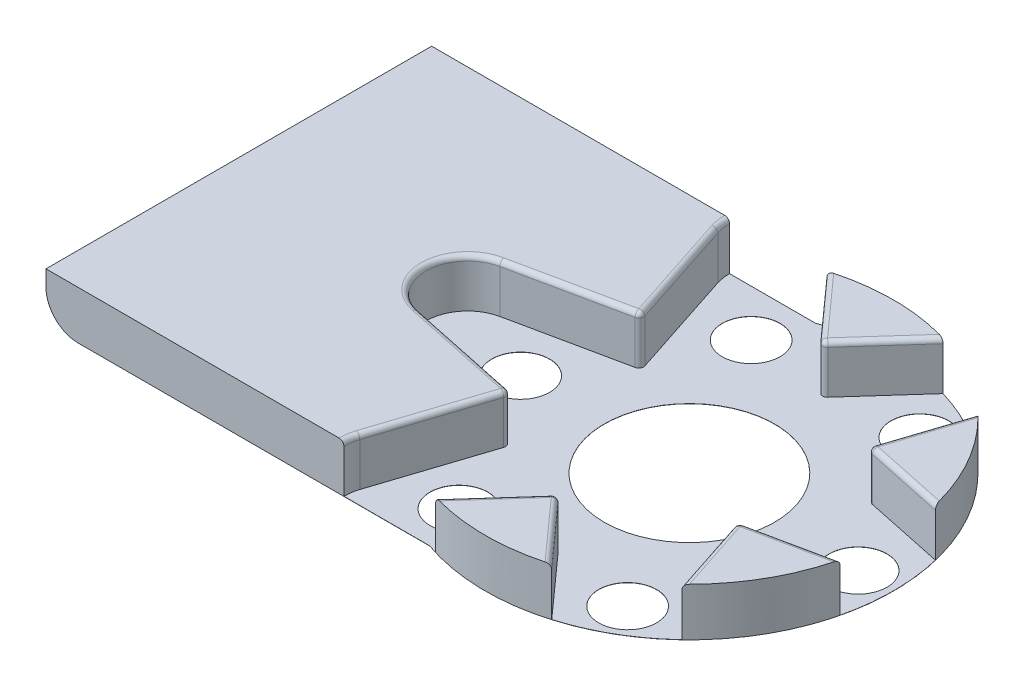
from build123d import *

# Parameters (mm, degrees)
CROQUIS1_R              = 5.3
SALIENTE_EXTRUIR1_DEPTH = 3
CORTAR_EXTRUIR2_DEPTH   = 2.99
REDONDEO1_R             = 2
REDONDEO2_R             = 0.3
CROQUIS3_R              = 1.8
CORTAR_EXTRUIR3_DEPTH   = 10
MATRIZC1_COUNT          = 6


with BuildPart() as part:
    # Croquis1 → Saliente-Extruir1 (new body)
    with BuildSketch(Plane(origin=(0, 0, 0), x_dir=(1, 0, 0), z_dir=(0, 1, 0))):
        with BuildLine():
            Line((-28.04, 12), (-4.158124577, 12))
            ThreePointArc((-4.158124577, 12), (12.7, 0), (-4.158124577, -12))
            Line((-4.158124577, -12), (-28.04, -12))
            Line((-28.04, -12), (-28.04, 12))
        make_face()
        Circle(CROQUIS1_R, mode=Mode.SUBTRACT)
    extrude(amount=SALIENTE_EXTRUIR1_DEPTH)

    # Croquis2 → Cortar-Extruir2 (cut)
    with BuildSketch(Plane(origin=(0, 3, 0), x_dir=(1, 0, 0), z_dir=(0, 1, 0))):
        with BuildLine():
            Line((-14.335178977, -2.544323773), (-7.058107041, -4.075))
            Line((-7.058107041, -4.075), (-9.371038511, -11.142467275))
            ThreePointArc((-9.371038511, -11.142467275), (-8.2, -14.202816622), (-4.964140465, -13.686791048))
            Line((-4.964140465, -13.686791048), (0, -8.15))
            Line((0, -8.15), (4.964140465, -13.686791048))
            ThreePointArc((4.964140465, -13.686791048), (8.2, -14.202816622), (9.371038511, -11.142467275))
            Line((9.371038511, -11.142467275), (7.058107041, -4.075))
            Line((7.058107041, -4.075), (14.335178977, -2.544323773))
            ThreePointArc((14.335178977, -2.544323773), (16.4, 0), (14.335178977, 2.544323773))
            Line((14.335178977, 2.544323773), (7.058107041, 4.075))
            Line((7.058107041, 4.075), (9.371038511, 11.142467275))
            ThreePointArc((9.371038511, 11.142467275), (8.2, 14.202816622), (4.964140465, 13.686791048))
            Line((4.964140465, 13.686791048), (0, 8.15))
            Line((0, 8.15), (-4.964140465, 13.686791048))
            ThreePointArc((-4.964140465, 13.686791048), (-8.2, 14.202816622), (-9.371038511, 11.142467275))
            Line((-9.371038511, 11.142467275), (-7.058107041, 4.075))
            Line((-7.058107041, 4.075), (-14.335178977, 2.544323773))
            ThreePointArc((-14.335178977, 2.544323773), (-16.4, 0), (-14.335178977, -2.544323773))
        make_face()
    extrude(amount=-CORTAR_EXTRUIR2_DEPTH, mode=Mode.SUBTRACT)

    # Redondeo1
    redondeo1_edges = [part.edges().sort_by_distance(p)[0] for p in [
        (-28.04, 0, 0),
    ]]
    fillet(redondeo1_edges, radius=REDONDEO1_R)

    # Redondeo2
    redondeo2_edges = [part.edges().sort_by_distance(p)[0] for p in [
        (0, 1.505, -8.15),
        (7.058107041, 1.505, -4.075),
        (7.058107041, 1.505, 4.075),
        (0, 1.505, 8.15),
        (1.804886558, 3, 10.163093668),
        (7.899054019, 3, 6.644624444),
        (9.703940577, 3, 3.518469224),
        (9.703940577, 3, -3.518469224),
        (7.899054019, 3, -6.644624444),
        (1.804886558, 3, -10.163093668),
        (-1.804886558, 3, -10.163093668),
        (-9.471290512, 3, -11.565838876),
        (-8.214572776, 3, -7.608733638),
        (-10.696643009, 3, -3.309661887),
        (-16.4, 3, 0),
        (-10.696643009, 3, 3.309661887),
        (-8.214572776, 3, 7.608733638),
        (-9.471290512, 3, 11.565838876),
        (-1.804886558, 3, 10.163093668),
        (-7.058107041, 1.505, -4.075),
        (-7.058107041, 1.505, 4.075),
    ]]
    fillet(redondeo2_edges, radius=REDONDEO2_R)

    # Croquis3 → Cortar-Extruir3 (cut)
    with BuildSketch(Plane.XZ):
        with Locations((10.5, 0)):
            Circle(CROQUIS3_R)
    cortar_extruir3 = extrude(amount=-CORTAR_EXTRUIR3_DEPTH, mode=Mode.SUBTRACT)

    # MatrizC1: Cortar-Extruir3 ×6 about axis
    matrizc1_axis = Axis((0, 0, 0), (0, 1, 0))
    for i in range(1, MATRIZC1_COUNT):
        add(cortar_extruir3.rotate(matrizc1_axis, i * 360 / MATRIZC1_COUNT), mode=Mode.SUBTRACT)


solid = part.part
